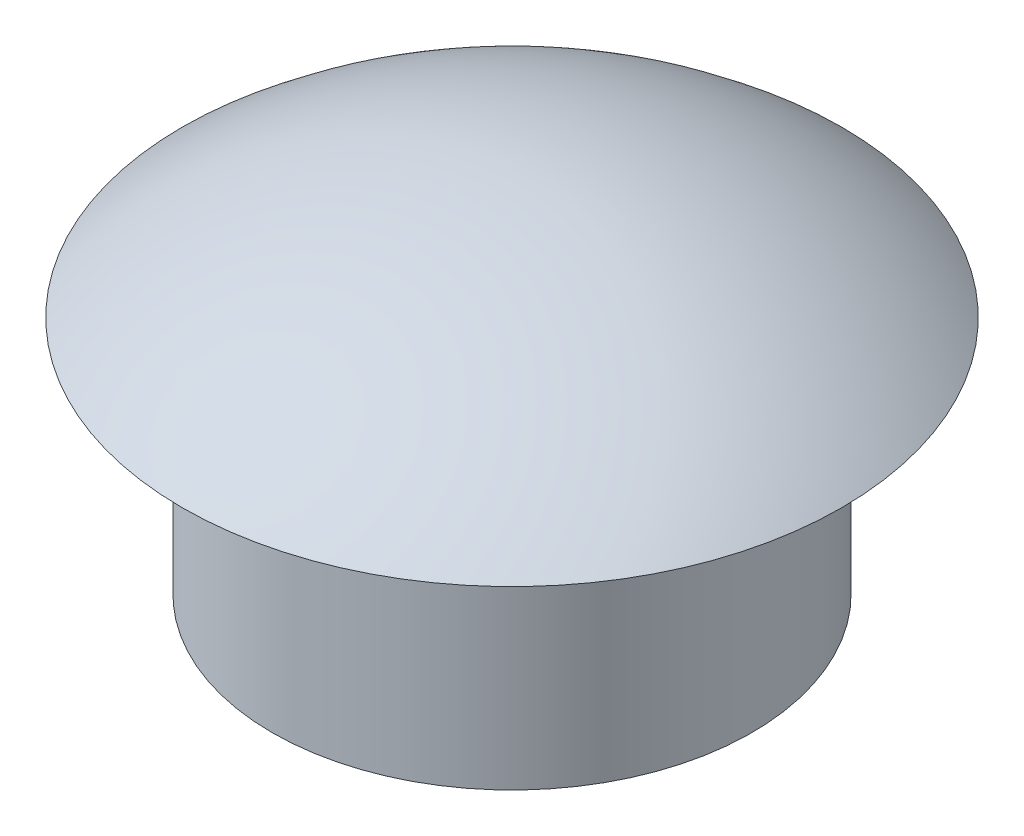
from build123d import *

# Parameters (mm, degrees)
SKETCH1_R           = 6.35
SKETCH1_R_2         = 4.7625
BOSS_EXTRUDE1_DEPTH = 6.35
SKETCH4_R           = 0.79375


with BuildPart() as part:
    # Sketch1 → Boss-Extrude1 (new body)
    with BuildSketch(Plane(origin=(0, 0, 0), x_dir=(1, 0, 0), z_dir=(0, 1, 0))):
        Circle(SKETCH1_R)
        Circle(SKETCH1_R_2, mode=Mode.SUBTRACT)
    extrude(amount=BOSS_EXTRUDE1_DEPTH)

    # Sketch2 → Revolve1 (revolve)
    with BuildSketch(Plane.XY):
        with BuildLine():
            Line((0, 9.525), (0, 6.35))
            Line((0, 6.35), (8.73125, 6.35))
            ThreePointArc((8.73125, 6.35), (4.645302777, 8.706613887), (0, 9.525))
        make_face()
    revolve(axis=Axis((0, 9.525, 0), (0, -1, 0)))

    # Sweep1: sweep along a path in Sketch3
    with BuildLine(Plane.XY) as sweep1_path:
        ThreePointArc((3.862295552, 6.35), (0, 2.487704448), (-3.862295552, 6.35))
    # Sketch4 → Sweep1 (sweep)
    with BuildSketch(Plane.XZ.offset(-6.35)):
        with Locations((3.862295552, 0)):
            Circle(SKETCH4_R)
    sweep(path=sweep1_path.line)


solid = part.part
